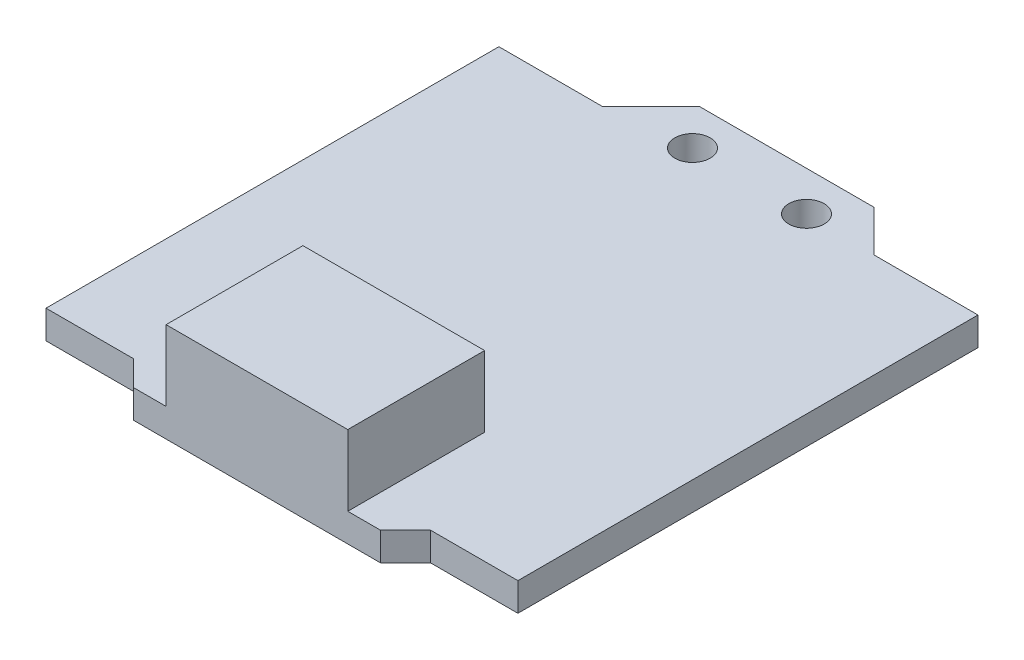
from build123d import *

# Parameters (mm, degrees)
BOSS_EXTRUDE1_DEPTH = 1.2
SKETCH2_W           = 7.7
SKETCH2_H           = 5.8
BOSS_EXTRUDE2_DEPTH = 3
SKETCH5_R           = 0.75
CUT_EXTRUDE1_DEPTH  = 3


with BuildPart() as part:
    # Sketch1 → Boss-Extrude1 (new body)
    with BuildSketch(Plane(origin=(0, 0, 0), x_dir=(1, 0, 0), z_dir=(0, 1, 0))):
        Polygon((-13.031308411, -6.656542056), (-13.031308411, 12.537383178), (-8.631308411, 12.537383178), (-6.575233645, 14.593457944), (0.818691589, 14.593457944), (2.568691589, 12.843457944), (6.968691589, 12.843457944), (6.968691589, -6.656542056), (3.268691589, -6.656542056), (2.208031417, -7.717202228), (-8.270648239, -7.717202228), (-9.331308411, -6.656542056), align=None)
    extrude(amount=BOSS_EXTRUDE1_DEPTH)

    # Sketch2 → Boss-Extrude2 (add)
    with BuildSketch(Plane(origin=(0, 1.2, 0), x_dir=(1, 0, 0), z_dir=(0, 1, 0))):
        with Locations((-3.031308411, -4.817202228)):
            Rectangle(SKETCH2_W, SKETCH2_H)
    extrude(amount=BOSS_EXTRUDE2_DEPTH)

    # Sketch5 → Cut-Extrude1 (cut)
    with BuildSketch(Plane(origin=(0, 1.2, 0), x_dir=(1, 0, 0), z_dir=(0, 1, 0))):
        with Locations((-5.209653936, 12.920685244)):
            Circle(SKETCH5_R)
        with Locations((-0.377462837, 12.920685244)):
            Circle(SKETCH5_R)
    extrude(amount=-CUT_EXTRUDE1_DEPTH, mode=Mode.SUBTRACT)


solid = part.part
